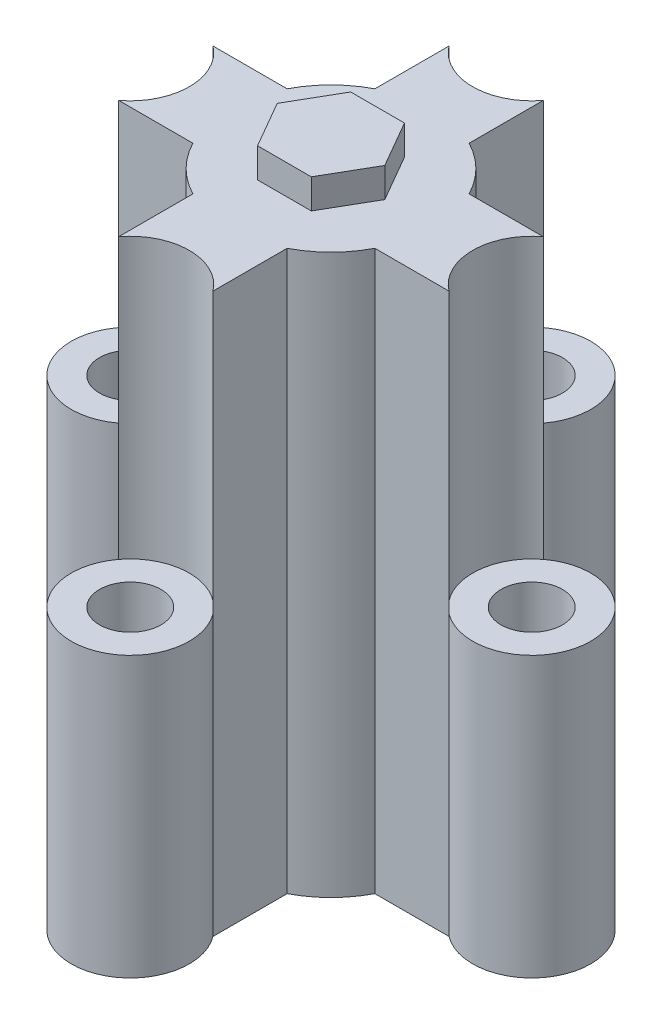
from build123d import *

# Parameters (mm, degrees)
BOSS_EXTRUDE1_DEPTH = 60
SKETCH1_3_R         = 6.339
SKETCH1_3_R_2       = 3.302
BOSS_EXTRUDE2_DEPTH = 30
BOSS_EXTRUDE3_DEPTH = 3.175


with BuildPart() as part:
    # Sketch1 → Boss-Extrude1 (new body)
    with BuildSketch(Plane(origin=(0, 0, 0), x_dir=(1, 0, 0), z_dir=(0, 1, 0))):
        with BuildLine():
            ThreePointArc((17.727459811, -5.058299483), (15.209, 0), (17.727459811, 5.058299483))
            Line((17.727459811, 5.058299483), (9.767988858, 5.058299483))
            ThreePointArc((9.767988858, 5.058299483), (7.778174593, 7.778174593), (5.058299483, 9.767988858))
            Line((5.058299483, 9.767988858), (5.058299483, 17.727459811))
            ThreePointArc((5.058299483, 17.727459811), (0, 15.209), (-5.058299483, 17.727459811))
            Line((-5.058299483, 17.727459811), (-5.058299483, 9.767988858))
            ThreePointArc((-5.058299483, 9.767988858), (-7.778174593, 7.778174593), (-9.767988858, 5.058299483))
            Line((-9.767988858, 5.058299483), (-17.727459811, 5.058299483))
            ThreePointArc((-17.727459811, 5.058299483), (-15.209, 0), (-17.727459811, -5.058299483))
            Line((-17.727459811, -5.058299483), (-9.767988858, -5.058299483))
            ThreePointArc((-9.767988858, -5.058299483), (-7.778174593, -7.778174593), (-5.058299483, -9.767988858))
            Line((-5.058299483, -9.767988858), (-5.058299483, -17.727459811))
            ThreePointArc((-5.058299483, -17.727459811), (0, -15.209), (5.058299483, -17.727459811))
            Line((5.058299483, -17.727459811), (5.058299483, -9.767988858))
            ThreePointArc((5.058299483, -9.767988858), (7.778174593, -7.778174593), (9.767988858, -5.058299483))
            Line((9.767988858, -5.058299483), (17.727459811, -5.058299483))
        make_face()
    extrude(amount=BOSS_EXTRUDE1_DEPTH)

    # Sketch1_3 → Boss-Extrude2 (add)
    # profile 1 of 4: a face of its own
    with BuildSketch(Plane(origin=(0, 0, 0), x_dir=(1, 0, 0), z_dir=(0, 1, 0))):
        with Locations((21.548, 0)):
            Circle(SKETCH1_3_R)
        with Locations((21.548, 0)):
            Circle(SKETCH1_3_R_2, mode=Mode.SUBTRACT)
    # profile 2 of 4: a face of its own
    with BuildSketch(Plane(origin=(0, 0, 0), x_dir=(1, 0, 0), z_dir=(0, 1, 0))):
        with Locations((0, 21.548)):
            Circle(SKETCH1_3_R)
        with Locations((0, 21.548)):
            Circle(SKETCH1_3_R_2, mode=Mode.SUBTRACT)
    # profile 3 of 4: a face of its own
    with BuildSketch(Plane(origin=(0, 0, 0), x_dir=(1, 0, 0), z_dir=(0, 1, 0))):
        with Locations((0, -21.548)):
            Circle(SKETCH1_3_R)
        with Locations((0, -21.548)):
            Circle(SKETCH1_3_R_2, mode=Mode.SUBTRACT)
    # profile 4 of 4: a face of its own
    with BuildSketch(Plane(origin=(0, 0, 0), x_dir=(1, 0, 0), z_dir=(0, 1, 0))):
        with Locations((-21.548, 0)):
            Circle(SKETCH1_3_R)
        with Locations((-21.548, 0)):
            Circle(SKETCH1_3_R_2, mode=Mode.SUBTRACT)
    extrude(amount=BOSS_EXTRUDE2_DEPTH)

    # Sketch2 → Boss-Extrude3 (add)
    with BuildSketch(Plane(origin=(0, 60, 0), x_dir=(1, 0, 0), z_dir=(0, 1, 0))):
        Polygon((5.773502692, 0), (2.886751346, 5), (-2.886751346, 5), (-5.773502692, 0), (-2.886751346, -5), (2.886751346, -5), align=None)
    extrude(amount=BOSS_EXTRUDE3_DEPTH)


solid = part.part
